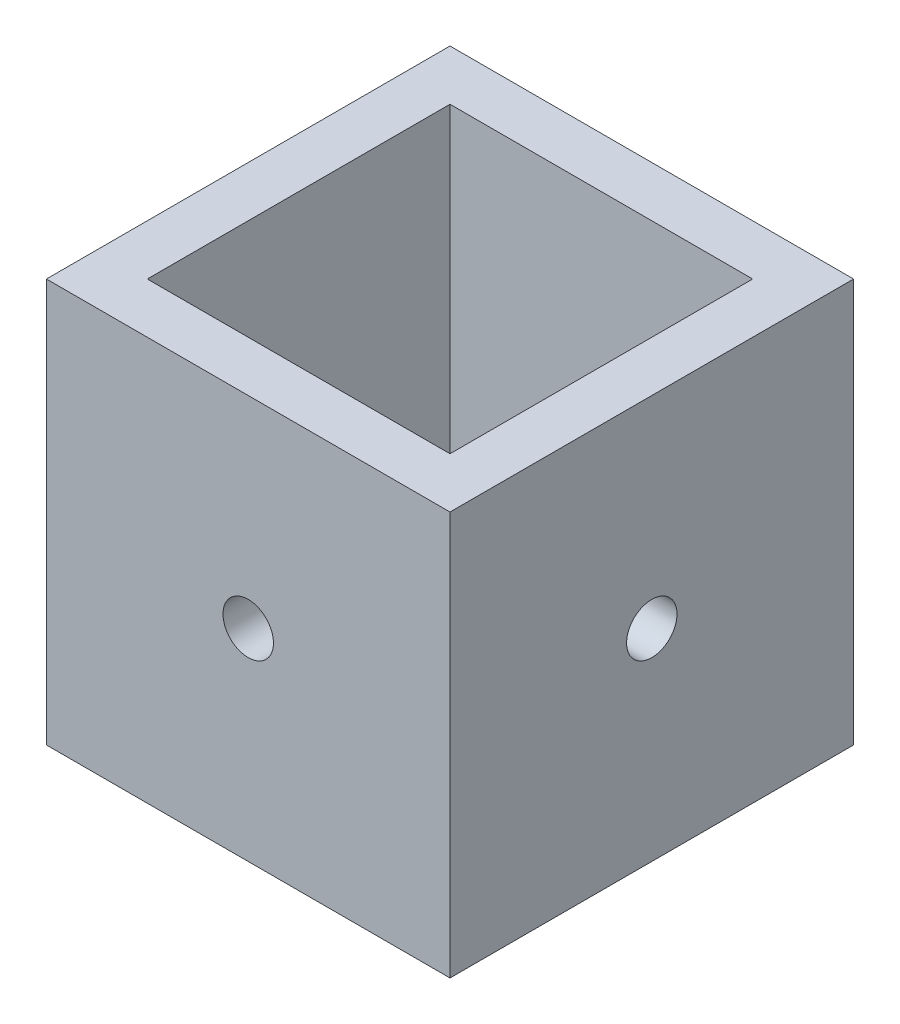
from build123d import *

# Parameters (mm, degrees)
SKETCH_5_W          = 25.4
SKETCH_5_H          = 25.4
SKETCH_5_W_2        = 19.05
SKETCH_5_H_2        = 19.05
EXTRUDE_1_DEPTH     = 25.4
SKETCH_6_R          = 1.5875
CUT_EXTRUDE_1_DEPTH = 30.48
SKETCH_7_R          = 1.5875
CUT_EXTRUDE_2_DEPTH = 30.48


with BuildPart() as part:
    # 스케치5 → 보스-돌출1 (new body)
    with BuildSketch(Plane(origin=(0, 0, 0), x_dir=(1, 0, 0), z_dir=(0, 1, 0))):
        Rectangle(SKETCH_5_W, SKETCH_5_H)
        Rectangle(SKETCH_5_W_2, SKETCH_5_H_2, mode=Mode.SUBTRACT)
    extrude(amount=EXTRUDE_1_DEPTH)

    # 스케치6 → 컷-돌출1 (cut)
    with BuildSketch(Plane.XY.offset(12.7)):
        with Locations((0, 12.7)):
            Circle(SKETCH_6_R)
    extrude(amount=-CUT_EXTRUDE_1_DEPTH, mode=Mode.SUBTRACT)

    # 스케치7 → 컷-돌출2 (cut)
    with BuildSketch(Plane(origin=(12.7, 0, 0), x_dir=(0, 0, -1), z_dir=(1, 0, 0))):
        with Locations((0, 12.7)):
            Circle(SKETCH_7_R)
    extrude(amount=-CUT_EXTRUDE_2_DEPTH, mode=Mode.SUBTRACT)


solid = part.part
